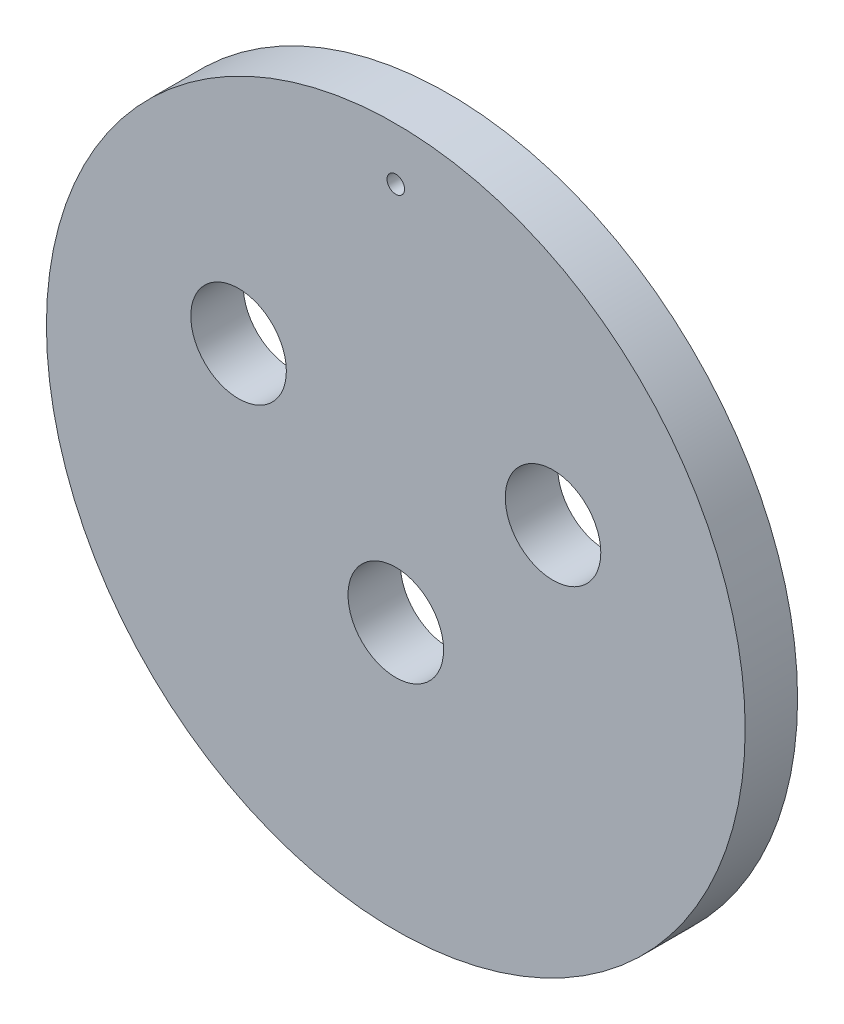
from build123d import *

# Parameters (mm, degrees)
SKETCH1_R           = 20
BOSS_EXTRUDE1_DEPTH = 3
SKETCH3_R           = 2.735
CUT_EXTRUDE1_DEPTH  = 10
SKETCH4_R           = 0.5
CUT_EXTRUDE2_DEPTH  = 10


with BuildPart() as part:
    # Sketch1 → Boss-Extrude1 (new body)
    with BuildSketch(Plane.XY):
        Circle(SKETCH1_R)
    extrude(amount=BOSS_EXTRUDE1_DEPTH)

    # Sketch3 → Cut-Extrude1 (cut)
    with BuildSketch(Plane.XY.offset(3)):
        with Locations((0, -4.723654738)):
            Circle(SKETCH3_R)
        with Locations((9, 4.6)):
            Circle(SKETCH3_R)
        with Locations((-9, 4.6)):
            Circle(SKETCH3_R)
    extrude(amount=-CUT_EXTRUDE1_DEPTH, mode=Mode.SUBTRACT)

    # Sketch4 → Cut-Extrude2 (cut)
    with BuildSketch(Plane.XY.offset(3)):
        with Locations((0, 17)):
            Circle(SKETCH4_R)
    extrude(amount=-CUT_EXTRUDE2_DEPTH, mode=Mode.SUBTRACT)


solid = part.part
